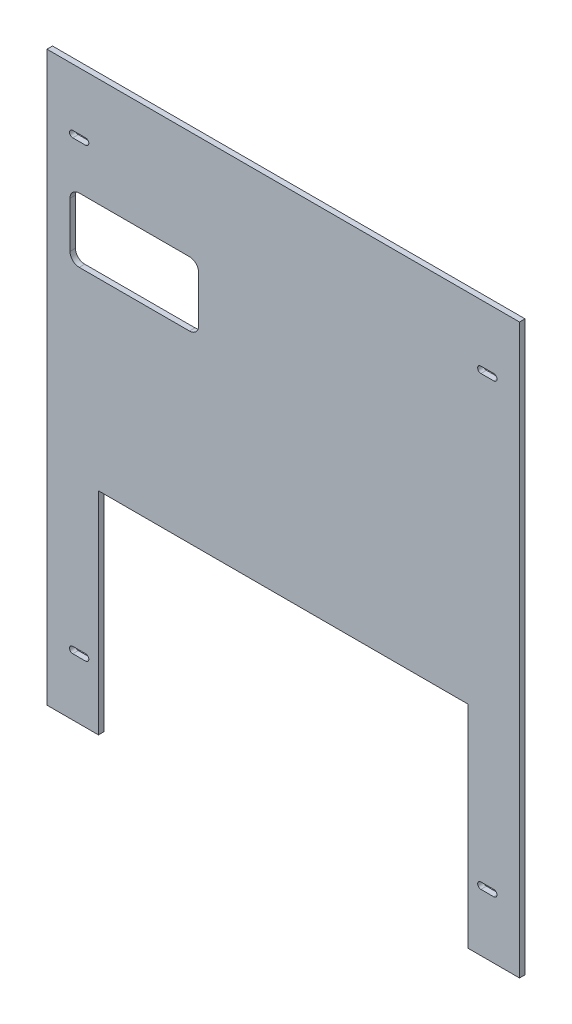
from build123d import *

# Parameters (mm, degrees)
ESQUISSE1_W             = 257
ESQUISSE1_H             = 309
BOSS_EXTRU_1_DEPTH      = 3
ESQUISSE2_W             = 201
ESQUISSE2_H             = 115
ENL_V_MAT_EXTRU_1_DEPTH = 4
ENL_V_MAT_EXTRU_2_DEPTH = 4


with BuildPart() as part:
    # Esquisse1 → Boss.-Extru.1 (new body)
    with BuildSketch(Plane.XY):
        Rectangle(ESQUISSE1_W, ESQUISSE1_H)
        with BuildLine():
            Line((-114.5, 123.25), (-107.5, 123.25))
            ThreePointArc((-107.5, 123.25), (-105.75, 121.5), (-107.5, 119.75))
            Line((-107.5, 119.75), (-114.5, 119.75))
            ThreePointArc((-114.5, 119.75), (-116.25, 121.5), (-114.5, 123.25))
        make_face(mode=Mode.SUBTRACT)
        with BuildLine():
            Line((107.5, -119.75), (114.5, -119.75))
            ThreePointArc((114.5, -119.75), (116.25, -121.5), (114.5, -123.25))
            Line((114.5, -123.25), (107.5, -123.25))
            ThreePointArc((107.5, -123.25), (105.75, -121.5), (107.5, -119.75))
        make_face(mode=Mode.SUBTRACT)
        with BuildLine():
            Line((-114.5, -119.75), (-107.5, -119.75))
            ThreePointArc((-107.5, -119.75), (-105.75, -121.5), (-107.5, -123.25))
            Line((-107.5, -123.25), (-114.5, -123.25))
            ThreePointArc((-114.5, -123.25), (-116.25, -121.5), (-114.5, -119.75))
        make_face(mode=Mode.SUBTRACT)
        with BuildLine():
            Line((107.5, 123.25), (114.5, 123.25))
            ThreePointArc((114.5, 123.25), (116.25, 121.5), (114.5, 119.75))
            Line((114.5, 119.75), (107.5, 119.75))
            ThreePointArc((107.5, 119.75), (105.75, 121.5), (107.5, 123.25))
        make_face(mode=Mode.SUBTRACT)
    extrude(amount=BOSS_EXTRU_1_DEPTH)

    # Esquisse2 → Enlèv. mat.-Extru.1 (cut, through all)
    with BuildSketch(Plane.XY.offset(3)):
        with Locations((0, -97)):
            Rectangle(ESQUISSE2_W, ESQUISSE2_H)
    extrude(amount=-ENL_V_MAT_EXTRU_1_DEPTH, mode=Mode.SUBTRACT)

    # Esquisse3 → Enlèv. mat.-Extru.2 (cut, through all)
    with BuildSketch(Plane.XY.offset(3)):
        with BuildLine():
            Line((-111, 60.5), (-51, 60.5))
            ThreePointArc((-51, 60.5), (-47.464466094, 61.964466094), (-46, 65.5))
            Line((-46, 65.5), (-46, 90.5))
            ThreePointArc((-46, 90.5), (-47.464466094, 94.035533906), (-51, 95.5))
            Line((-51, 95.5), (-111, 95.5))
            ThreePointArc((-111, 95.5), (-114.535533906, 94.035533906), (-116, 90.5))
            Line((-116, 90.5), (-116, 65.5))
            ThreePointArc((-116, 65.5), (-114.535533906, 61.964466094), (-111, 60.5))
        make_face()
    extrude(amount=-ENL_V_MAT_EXTRU_2_DEPTH, mode=Mode.SUBTRACT)


solid = part.part
